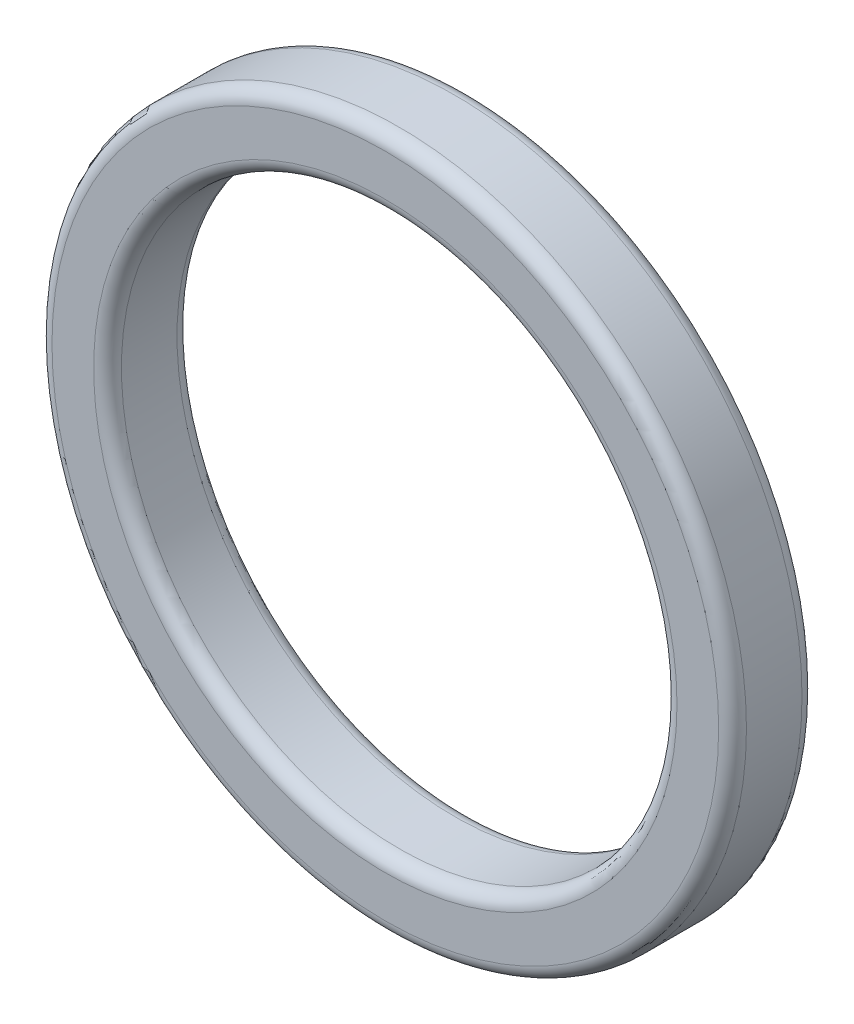
from build123d import *

# Parameters (mm, degrees)
SKETCH_1_R      = 25
SKETCH_1_R_2    = 20
EXTRUDE_1_DEPTH = 6
FILLET_1_R      = 1


with BuildPart() as part:
    # ｽｹｯﾁ1 → ﾎﾞｽ - 押し出し1 (new body)
    with BuildSketch(Plane.XY):
        Circle(SKETCH_1_R)
        Circle(SKETCH_1_R_2, mode=Mode.SUBTRACT)
    extrude(amount=EXTRUDE_1_DEPTH)

    # ﾌｨﾚｯﾄ1
    fillet_1_edges = [part.edges().sort_by_distance(p)[0] for p in [
        (-25, 0, 0),
        (-25, 0, 6),
        (-20, 0, 0),
        (-20, 0, 6),
    ]]
    fillet(fillet_1_edges, radius=FILLET_1_R)


solid = part.part
